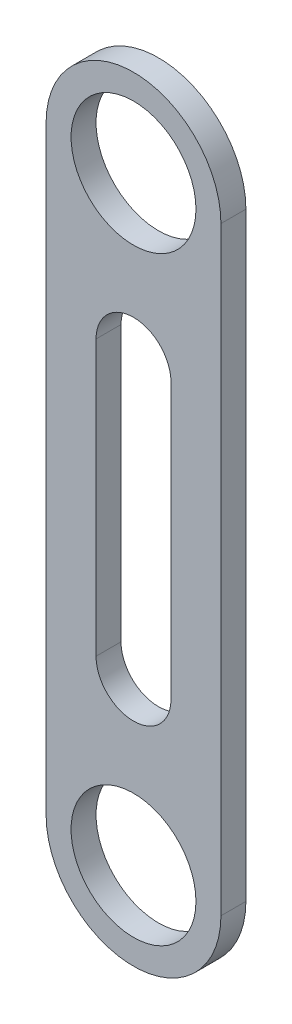
from build123d import *

# Parameters (mm, degrees)
SKETCH1_R           = 7.9375
BOSS_EXTRUDE1_DEPTH = 3.175


with BuildPart() as part:
    # Sketch1 → Boss-Extrude1 (new body)
    with BuildSketch(Plane.XY):
        with BuildLine():
            ThreePointArc((11.1125, 76.2), (0, 87.3125), (-11.1125, 76.2))
            Line((-11.1125, 76.2), (-11.1125, 0))
            ThreePointArc((-11.1125, 0), (0, -11.1125), (11.1125, 0))
            Line((11.1125, 0), (11.1125, 76.2))
        make_face()
        with Locations((0, 76.2)):
            Circle(SKETCH1_R, mode=Mode.SUBTRACT)
        with BuildLine():
            Line((-4.7625, 20.6375), (-4.7625, 55.5625))
            ThreePointArc((-4.7625, 55.5625), (0, 60.325), (4.7625, 55.5625))
            Line((4.7625, 55.5625), (4.7625, 20.6375))
            ThreePointArc((4.7625, 20.6375), (0, 15.875), (-4.7625, 20.6375))
        make_face(mode=Mode.SUBTRACT)
        Circle(SKETCH1_R, mode=Mode.SUBTRACT)
    extrude(amount=BOSS_EXTRUDE1_DEPTH)


solid = part.part
